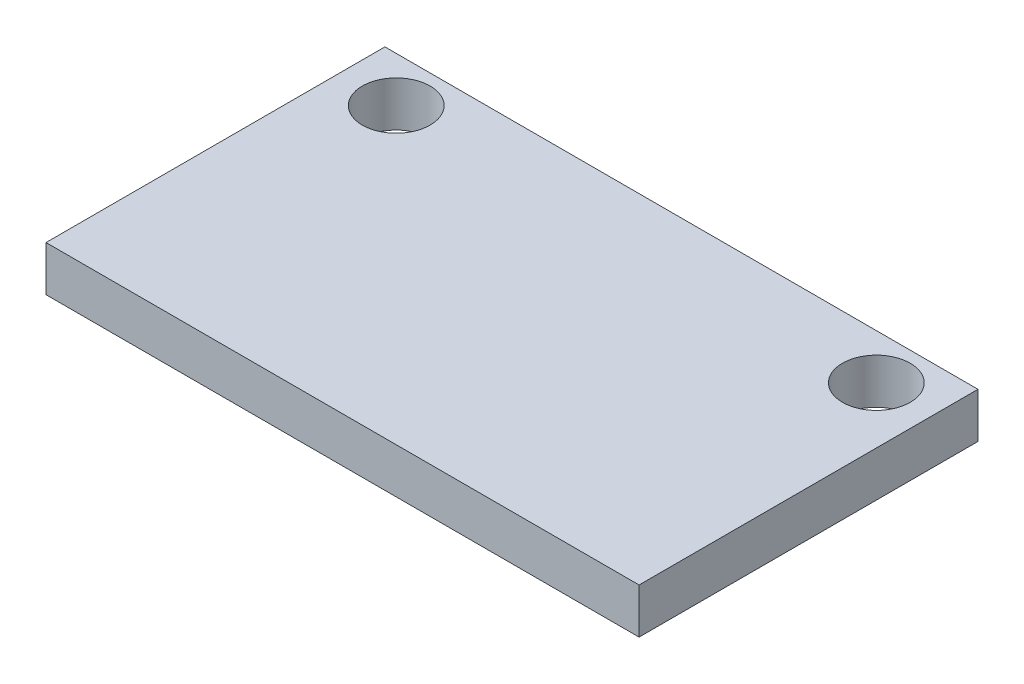
from build123d import *

# Parameters (mm, degrees)
SKETCH1_W           = 26.25
SKETCH1_H           = 15
SKETCH1_R           = 1.5
BOSS_EXTRUDE1_DEPTH = 1


with BuildPart() as part:
    # Sketch1 → Boss-Extrude1 (new body, symmetric)
    with BuildSketch(Plane(origin=(0, 0, 0), x_dir=(1, 0, 0), z_dir=(0, 1, 0))):
        Rectangle(SKETCH1_W, SKETCH1_H)
        with Locations((-10.625, 5.5)):
            Circle(SKETCH1_R, mode=Mode.SUBTRACT)
        with Locations((10.625, 5.5)):
            Circle(SKETCH1_R, mode=Mode.SUBTRACT)
    extrude(amount=BOSS_EXTRUDE1_DEPTH, both=True)


solid = part.part
